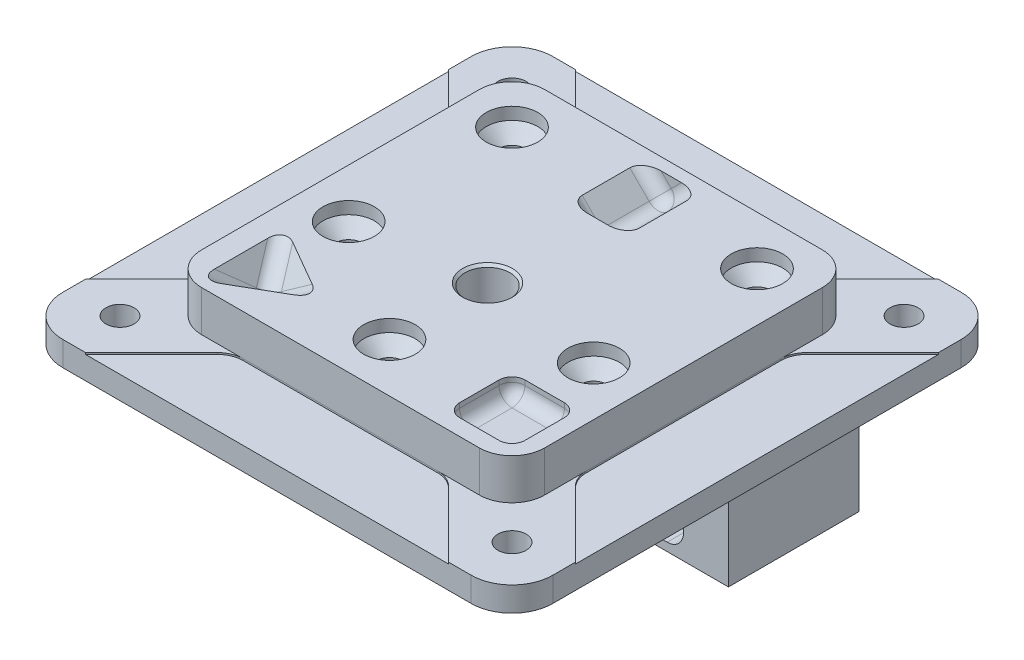
from build123d import *

# Parameters (mm, degrees)
SKETCH6_W                                      = 60
SKETCH6_H                                      = 60
PLATE_DEPTH                                    = 8
SKETCH7_W                                      = 60
SKETCH7_H                                      = 60
SKETCH7_W_2                                    = 42
SKETCH7_H_2                                    = 42
TOP_HAT_DEPTH                                  = 5
F_8_32_TAPPED_HOLE1_D                          = 3.4544
FILLET2_R                                      = 5
FILLET3_R                                      = 4
EXTRUDE8_DEPTH                                 = 0.2
BOSS_EXTRUDE1_DEPTH                            = 8
SKETCH25_R                                     = 1.986875
CUT_EXTRUDE1_DEPTH                             = 3.47375
CUT_EXTRUDE3_START                             = -19.986875
CUT_EXTRUDE3_DEPTH                             = 19.986875
FILLET4_R                                      = 1
BOSS_EXTRUDE2_DEPTH                            = 6.513125
F_4_40_TAPPED_HOLE2_D                          = 2.2606
F_4_40_TAPPED_HOLE2_DEPTH                      = 7.595
F_4_40_TAPPED_HOLE2_TIP                        = 0.679152758
CUT_EXTRUDE7_DEPTH                             = 10.25
SKETCH39_R                                     = 1.986875
CUT_EXTRUDE4_DEPTH                             = 10.25
CUT_EXTRUDE8_DEPTH                             = 5
BOSS_EXTRUDE3_DEPTH                            = 3
F_4_40_TAPPED_HOLE1_D                          = 2.2606
F_4_40_TAPPED_HOLE1_DEPTH                      = 7.595
F_4_40_TAPPED_HOLE1_TIP                        = 0.679152758
F_10_24_TAPPED_HOLE1_D                         = 3.7973
F_10_24_TAPPED_HOLE1_DEPTH                     = 15.878
F_10_24_TAPPED_HOLE1_CSINK_D                   = 6.096
F_10_24_TAPPED_HOLE1_CSINK_ANGLE               = 90
F_10_24_TAPPED_HOLE1_TIP                       = 1.140824014
PYR_DEPTH                                      = 40.339995873
SKETCH10_W                                     = 8
SKETCH10_H                                     = 8
EXTRUDE6_DEPTH                                 = 2.175
EXTRUDE7_DEPTH                                 = 4.5
FILLET1_R                                      = 1.5875
CUT_EXTRUDE13_DEPTH                            = 7
FILLET7_R                                      = 2
FILLET8_R                                      = 1
CSK_FOR_M3_FLAT_HEAD_MACHINE_SCREW1_AT_2_COUNT = 2
CSK_FOR_M3_FLAT_HEAD_MACHINE_SCREW1_AT_2_PITCH = 30
CSK_FOR_M3_FLAT_HEAD_MACHINE_SCREW1_AT_3_COUNT = 2
CSK_FOR_M3_FLAT_HEAD_MACHINE_SCREW1_AT_3_PITCH = 33.541019662
CSK_FOR_M3_FLAT_HEAD_MACHINE_SCREW1_AT_4_COUNT = 2
CSK_FOR_M3_FLAT_HEAD_MACHINE_SCREW1_AT_4_PITCH = 20
CSK_FOR_M3_FLAT_HEAD_MACHINE_SCREW1_AT_5_COUNT = 2
CSK_FOR_M3_FLAT_HEAD_MACHINE_SCREW1_AT_5_PITCH = 36.055512755
SKETCH61_W                                     = 1.25
SKETCH61_H                                     = 3
M3X0_5_TAPPED_HOLE2_AT_2_COUNT                 = 2
M3X0_5_TAPPED_HOLE2_AT_2_PITCH                 = 30
M3X0_5_TAPPED_HOLE2_AT_3_COUNT                 = 2
M3X0_5_TAPPED_HOLE2_AT_3_PITCH                 = 36.055512755
M3X0_5_TAPPED_HOLE2_AT_4_COUNT                 = 2
M3X0_5_TAPPED_HOLE2_AT_4_PITCH                 = 20
M3X0_5_TAPPED_HOLE2_AT_5_COUNT                 = 2
M3X0_5_TAPPED_HOLE2_AT_5_PITCH                 = 18.027756377
SKETCH63_R                                     = 2.75
CUT_EXTRUDE14_DEPTH                            = 29


with BuildPart() as part:
    # Sketch6 → plate (new body)
    with BuildSketch(Plane(origin=(0, 0, 0), x_dir=(1, 0, 0), z_dir=(0, 1, 0))):
        Rectangle(SKETCH6_W, SKETCH6_H)
    extrude(amount=PLATE_DEPTH)

    # Sketch7 → top hat (cut)
    with BuildSketch(Plane(origin=(0, 8, 0), x_dir=(1, 0, 0), z_dir=(0, 1, 0))):
        Rectangle(SKETCH7_W, SKETCH7_H)
        Rectangle(SKETCH7_W_2, SKETCH7_H_2, mode=Mode.SUBTRACT)
    extrude(amount=-TOP_HAT_DEPTH, mode=Mode.SUBTRACT)

    # #8-32 Tapped Hole1 (through all)
    with Locations(Plane(origin=(-24, 3, -24), x_dir=(0, 0, 1), z_dir=(0, 1, 0))):
        with Locations((0, 0), (0, 48), (48, 48), (48, 0)):
            Hole(F_8_32_TAPPED_HOLE1_D / 2)

    # Fillet2
    fillet2_edges = [part.edges().sort_by_distance(p)[0] for p in [
        (30, 1.5, 30),
        (-30, 1.5, 30),
        (-30, 1.5, -30),
        (30, 1.5, -30),
    ]]
    fillet(fillet2_edges, radius=FILLET2_R)

    # Fillet3
    fillet3_edges = [part.edges().sort_by_distance(p)[0] for p in [
        (-21, 5.5, 21),
        (-21, 5.5, -21),
        (21, 5.5, -21),
        (21, 5.5, 21),
    ]]
    fillet(fillet3_edges, radius=FILLET3_R)

    # Sketch15 → Extrude8 (cut)
    with BuildSketch(Plane(origin=(0, 3, 0), x_dir=(1, 0, 0), z_dir=(0, 1, 0))):
        with BuildLine():
            Line((30, 22.221825407), (30, -22.221825407))
            Line((30, -22.221825407), (21.92993597, -14.151761377))
            ThreePointArc((21.92993597, -14.151761377), (21.241682484, -13.121717244), (21, -11.906697346))
            Line((21, -11.906697346), (21, 11.906697346))
            ThreePointArc((21, 11.906697346), (21.241682484, 13.121717244), (21.92993597, 14.151761377))
            Line((21.92993597, 14.151761377), (30, 22.221825407))
        make_face()
        with BuildLine():
            Line((11.906697346, -21), (-11.906697346, -21))
            ThreePointArc((-11.906697346, -21), (-13.121717244, -21.241682484), (-14.151761377, -21.92993597))
            Line((-14.151761377, -21.92993597), (-22.221825407, -30))
            Line((-22.221825407, -30), (22.221825407, -30))
            Line((22.221825407, -30), (14.151761377, -21.92993597))
            ThreePointArc((14.151761377, -21.92993597), (13.121717244, -21.241682484), (11.906697346, -21))
        make_face()
        with BuildLine():
            Line((-30, -22.221825407), (-30, 22.221825407))
            Line((-30, 22.221825407), (-21.92993597, 14.151761377))
            ThreePointArc((-21.92993597, 14.151761377), (-21.241682484, 13.121717244), (-21, 11.906697346))
            Line((-21, 11.906697346), (-21, -11.906697346))
            ThreePointArc((-21, -11.906697346), (-21.241682484, -13.121717244), (-21.92993597, -14.151761377))
            Line((-21.92993597, -14.151761377), (-30, -22.221825407))
        make_face()
        with BuildLine():
            Line((22.221825407, 30), (-22.221825407, 30))
            Line((-22.221825407, 30), (-14.151761377, 21.92993597))
            ThreePointArc((-14.151761377, 21.92993597), (-13.121717244, 21.241682484), (-11.906697346, 21))
            Line((-11.906697346, 21), (11.906697346, 21))
            ThreePointArc((11.906697346, 21), (13.121717244, 21.241682484), (14.151761377, 21.92993597))
            Line((14.151761377, 21.92993597), (22.221825407, 30))
        make_face()
    extrude(amount=-EXTRUDE8_DEPTH, mode=Mode.SUBTRACT)



with BuildPart() as body_2:
    # Sketch24 → Boss-Extrude1 (new body, symmetric)
    with BuildSketch(Plane(origin=(-11, 0, 0), x_dir=(0, 0, -1), z_dir=(1, 0, 0))):
        Polygon((0.763125, 2.8), (23.486875, 2.8), (23.486875, -10.513125), (23.486875, -20), (-8, -20), (-8, 2.8), align=None)
    extrude(amount=BOSS_EXTRUDE1_DEPTH, both=True)

    # Sketch25 → Cut-Extrude1 (cut)
    with BuildSketch(Plane(origin=(0, 0, -23.486875), x_dir=(-1, 0, 0), z_dir=(0, 0, -1))):
        with Locations((16, -13)):
            Circle(SKETCH25_R)
        with Locations((6, -13)):
            Circle(SKETCH25_R)
    extrude(amount=-CUT_EXTRUDE1_DEPTH, mode=Mode.SUBTRACT)

    # Sketch26 → Cut-Extrude3 (cut)
    with BuildSketch(Plane(origin=(0, 0, -23.486875), x_dir=(-1, 0, 0), z_dir=(0, 0, -1)).offset(CUT_EXTRUDE3_START)):
        with BuildLine():
            Line((4.585786438, -10.525126266), (8.5, -14.439339828))
            Line((8.5, -14.439339828), (8.5, -17))
            ThreePointArc((8.5, -17), (9.085786438, -18.414213562), (10.5, -19))
            Line((10.5, -19), (11.5, -19))
            ThreePointArc((11.5, -19), (12.914213562, -18.414213562), (13.5, -17))
            Line((13.5, -17), (13.5, -14.439339828))
            Line((13.5, -14.439339828), (17.414213562, -10.525126266))
            ThreePointArc((17.414213562, -10.525126266), (17.847759065, -9.876279568), (18, -9.110912703))
            Line((18, -9.110912703), (18, -5.525126266))
            Line((18, -5.525126266), (18, -2))
            ThreePointArc((18, -2), (17.414213562, -0.585786438), (16, 0))
            Line((16, 0), (6, 0))
            ThreePointArc((6, 0), (4.585786438, -0.585786438), (4, -2))
            Line((4, -2), (4, -5.525126266))
            Line((4, -5.525126266), (4, -9.110912703))
            ThreePointArc((4, -9.110912703), (4.152240935, -9.876279568), (4.585786438, -10.525126266))
        make_face()
    extrude(amount=CUT_EXTRUDE3_DEPTH, mode=Mode.SUBTRACT)

    # Fillet4
    fillet4_edges = [body_2.edges().sort_by_distance(p)[0] for p in [
        (-8.5, -14.439339828, -13.4934375),
        (-13.5, -14.439339828, -13.4934375),
    ]]
    fillet(fillet4_edges, radius=FILLET4_R)


with BuildPart() as part_1:
    add(part.part)

    add(body_2.part)  # Boss-Extrude2 merges body 2
    # Sketch28 → Boss-Extrude2 (add)
    with BuildSketch(Plane(origin=(0, 0, -23.486875), x_dir=(-1, 0, 0), z_dir=(0, 0, -1))):
        with BuildLine():
            Line((4, -2), (4, -9.110912703))
            Line((4, -9.110912703), (3, -9.110912703))
            Line((3, -9.110912703), (3, 2.8))
            Line((3, 2.8), (19, 2.8))
            Line((19, 2.8), (19, -9.110912703))
            Line((19, -9.110912703), (18, -9.110912703))
            Line((18, -9.110912703), (18, -2))
            ThreePointArc((18, -2), (17.414213562, -0.585786438), (16, 0))
            Line((16, 0), (6, 0))
            ThreePointArc((6, 0), (4.585786438, -0.585786438), (4, -2))
        make_face()
    extrude(amount=BOSS_EXTRUDE2_DEPTH)

    # #4-40 Tapped Hole2
    with Locations(Plane(origin=(0, 0, -23.486875), x_dir=(-1, 0, 0), z_dir=(0, 0, -1))):
        with Locations((16, -17), (6, -17)):
            Hole(F_4_40_TAPPED_HOLE2_D / 2, depth=F_4_40_TAPPED_HOLE2_DEPTH)
            with Locations((0, 0, -(F_4_40_TAPPED_HOLE2_DEPTH + F_4_40_TAPPED_HOLE2_TIP / 2))):  # 118° drill point
                Cone(0, F_4_40_TAPPED_HOLE2_D / 2, F_4_40_TAPPED_HOLE2_TIP, mode=Mode.SUBTRACT)

    # Sketch44 → Cut-Extrude7 (cut)
    with BuildSketch(Plane.ZY.offset(19)):
        with BuildLine():
            Line((8, 0), (-3.5, 0))
            ThreePointArc((-3.5, 0), (-6.328427125, -1.171572875), (-7.5, -4))
            Line((-7.5, -4), (-7.5, -13))
            Line((-7.5, -13), (-7.5, -20))
            Line((-7.5, -20), (8, -20))
            Line((8, -20), (8, -17))
            Line((8, -17), (8, -13))
            Line((8, -13), (8, -4))
            Line((8, -4), (8, 0))
        make_face()
        with BuildLine():
            Line((1, -12.5), (-2.25, -12.5))
            ThreePointArc((-2.25, -12.5), (-3.133883476, -12.133883476), (-3.5, -11.25))
            Line((-3.5, -11.25), (-3.5, -5.75))
            ThreePointArc((-3.5, -5.75), (-3.133883476, -4.866116524), (-2.25, -4.5))
            Line((-2.25, -4.5), (1, -4.5))
            ThreePointArc((1, -4.5), (1.883883476, -4.866116524), (2.25, -5.75))
            Line((2.25, -5.75), (2.25, -11.25))
            ThreePointArc((2.25, -11.25), (1.883883476, -12.133883476), (1, -12.5))
        make_face(mode=Mode.SUBTRACT)
    extrude(amount=-CUT_EXTRUDE7_DEPTH, mode=Mode.SUBTRACT)

    # Sketch39 → Cut-Extrude4 (cut)
    with BuildSketch(Plane.ZY.offset(19)):
        with Locations((-2.75, -8.5)):
            Circle(SKETCH39_R)
    extrude(amount=-CUT_EXTRUDE4_DEPTH, mode=Mode.SUBTRACT)

    # Sketch45 → Cut-Extrude8 (cut)
    with BuildSketch(Plane.ZY.offset(19)):
        with BuildLine():
            Line((2.25, -11.25), (2.25, -5.75))
            ThreePointArc((2.25, -5.75), (1.883883476, -4.866116524), (1, -4.5))
            Line((1, -4.5), (-2.25, -4.5))
            ThreePointArc((-2.25, -4.5), (-3.133883476, -4.866116524), (-3.5, -5.75))
            Line((-3.5, -5.75), (-3.5, -6.660116236))
            ThreePointArc((-3.5, -6.660116236), (-0.763125, -8.5), (-3.5, -10.339883764))
            Line((-3.5, -10.339883764), (-3.5, -11.25))
            ThreePointArc((-3.5, -11.25), (-3.133883476, -12.133883476), (-2.25, -12.5))
            Line((-2.25, -12.5), (1, -12.5))
            ThreePointArc((1, -12.5), (1.883883476, -12.133883476), (2.25, -11.25))
        make_face()
    extrude(amount=-CUT_EXTRUDE8_DEPTH, mode=Mode.SUBTRACT)

    # Sketch38 → Boss-Extrude3 (add)
    with BuildSketch(Plane(origin=(-3, 0, 0), x_dir=(0, 0, -1), z_dir=(1, 0, 0))):
        Polygon((30, -9.110912703), (30, 0), (-8, 0), (-8, -20), (23.486875, -20), (23.486875, -9.110912703), align=None)
    extrude(amount=BOSS_EXTRUDE3_DEPTH)

    # #4-40 Tapped Hole1
    with Locations(Plane.ZY.offset(8.75)):
        with Locations((5.25, -16.5), (-0.75, -16.5)):
            Hole(F_4_40_TAPPED_HOLE1_D / 2, depth=F_4_40_TAPPED_HOLE1_DEPTH)
            with Locations((0, 0, -(F_4_40_TAPPED_HOLE1_DEPTH + F_4_40_TAPPED_HOLE1_TIP / 2))):  # 118° drill point
                Cone(0, F_4_40_TAPPED_HOLE1_D / 2, F_4_40_TAPPED_HOLE1_TIP, mode=Mode.SUBTRACT)


with BuildPart() as body_2_2:
    # Mirror11: mirrored copy
    add(part_1.part.mirror(Plane(origin=(0, 0, 0), x_dir=(0, 0, 1), z_dir=(1, 0, 0))))


with BuildPart() as part_2:
    add(part_1.part)

    # Combine1: union body 2 2
    add(body_2_2.part)

    # #10-24 Tapped Hole1
    with Locations(Plane(origin=(0, 8, 3), x_dir=(0, 0, 1), z_dir=(0, 1, 0))):
        with Locations((0, 0)):
            CounterSinkHole(F_10_24_TAPPED_HOLE1_D / 2, F_10_24_TAPPED_HOLE1_CSINK_D / 2, depth=F_10_24_TAPPED_HOLE1_DEPTH, counter_sink_angle=F_10_24_TAPPED_HOLE1_CSINK_ANGLE)
            with Locations((0, 0, -(F_10_24_TAPPED_HOLE1_DEPTH + F_10_24_TAPPED_HOLE1_TIP / 2))):  # 118° drill point
                Cone(0, F_10_24_TAPPED_HOLE1_D / 2, F_10_24_TAPPED_HOLE1_TIP, mode=Mode.SUBTRACT)

    # Sketch9 → pyr (cut, through all)
    with BuildSketch(Plane(origin=(-8.349735957, -5.904154917, 0), x_dir=(0, 0, -1), z_dir=(0.816496581, 0.577350269, 0))):
        Polygon((-20.510447219, 17.029042425), (-9.489552781, 17.029042425), (-15, 11.518595206), align=None)
    extrude(amount=PYR_DEPTH, mode=Mode.SUBTRACT)

    # Sketch10 → Extrude6 (cut)
    with BuildSketch(Plane(origin=(0, 8, 0), x_dir=(1, 0, 0), z_dir=(0, 1, 0))):
        with Locations((15, -15)):
            Rectangle(SKETCH10_W, SKETCH10_H)
    extrude(amount=-EXTRUDE6_DEPTH, mode=Mode.SUBTRACT)

    # Sketch11 → Extrude7 (cut, symmetric)
    with BuildSketch(Plane.XY.offset(-15)):
        Polygon((-7.665128061, 12.175), (7.665128061, 12.175), (0, 4.509871939), align=None)
    extrude(amount=EXTRUDE7_DEPTH, both=True, mode=Mode.SUBTRACT)

    # Fillet1
    fillet1_edges = [part_2.edges().sort_by_distance(p)[0] for p in [
        (-16.590729093, 5.750369343, 17.75522361),
        (-16.590729093, 5.750369343, 12.24477639),
        (-11.818541815, 5.750369343, 15),
        (11, 5.825, 15),
        (11, 6.9125, 19),
        (15, 5.825, 11),
        (11, 6.9125, 11),
        (19, 5.825, 15),
        (19, 6.9125, 11),
        (15, 5.825, 19),
        (19, 6.9125, 19),
        (-1.74506403, 6.25493597, -19.5),
        (0, 4.509871939, -15),
        (1.74506403, 6.25493597, -19.5),
        (-1.74506403, 6.25493597, -10.5),
        (1.74506403, 6.25493597, -10.5),
    ]]
    fillet(fillet1_edges, radius=FILLET1_R)

    # Sketch62 → Cut-Extrude13 (cut)
    with BuildSketch(Plane.XZ.offset(20)):
        Polygon((2, -4), (5.25, -4), (5.25, 8), (-5.25, 8), (-5.25, -4), (-2, -4), (-2, -23.486875), (2, -23.486875), align=None)
    extrude(amount=-CUT_EXTRUDE13_DEPTH, mode=Mode.SUBTRACT)

    # Fillet7
    fillet7_edges = [part_2.edges().sort_by_distance(p)[0] for p in [
        (-5.25, -16.5, -4),
        (5.25, -16.5, -4),
    ]]
    fillet(fillet7_edges, radius=FILLET7_R)

    # Fillet8
    fillet8_edges = [part_2.edges().sort_by_distance(p)[0] for p in [
        (2, -16.5, -4),
        (-2, -16.5, -4),
    ]]
    fillet(fillet8_edges, radius=FILLET8_R)


with BuildPart() as body_2_3:
    # Split1: the piece on the far side of the plane
    add(part_2.part)
    split(bisect_by=Plane.ZX.offset(3), keep=Keep.BOTTOM)

    # Sketch61 → M3x0.5 Tapped Hole2 (revolve, cut)
    with BuildSketch(Plane(origin=(15, 3, 5), x_dir=(0, 0, 1), z_dir=(1, 0, 0))):
        with Locations((0.625, 1.5)):
            Rectangle(SKETCH61_W, SKETCH61_H)
    m3x0_5_tapped_hole2 = revolve(axis=Axis((15, 9.35, 5), (0, -1, 0)), mode=Mode.SUBTRACT)

    # M3x0.5 Tapped Hole2 at 2: M3x0.5 Tapped Hole2 ×2
    with Locations(*[(-i * M3X0_5_TAPPED_HOLE2_AT_2_PITCH, 0, 0) for i in range(1, M3X0_5_TAPPED_HOLE2_AT_2_COUNT)]):
        add(m3x0_5_tapped_hole2, mode=Mode.SUBTRACT)

    # M3x0.5 Tapped Hole2 at 3: M3x0.5 Tapped Hole2 ×2
    with Locations(*[Vector(-0.832050294, 0, -0.554700196) * (i * M3X0_5_TAPPED_HOLE2_AT_3_PITCH) for i in range(1, M3X0_5_TAPPED_HOLE2_AT_3_COUNT)]):
        add(m3x0_5_tapped_hole2, mode=Mode.SUBTRACT)

    # M3x0.5 Tapped Hole2 at 4: M3x0.5 Tapped Hole2 ×2
    with Locations(*[(0, 0, -i * M3X0_5_TAPPED_HOLE2_AT_4_PITCH) for i in range(1, M3X0_5_TAPPED_HOLE2_AT_4_COUNT)]):
        add(m3x0_5_tapped_hole2, mode=Mode.SUBTRACT)

    # M3x0.5 Tapped Hole2 at 5: M3x0.5 Tapped Hole2 ×2
    with Locations(*[Vector(-0.832050294, 0, 0.554700196) * (i * M3X0_5_TAPPED_HOLE2_AT_5_PITCH) for i in range(1, M3X0_5_TAPPED_HOLE2_AT_5_COUNT)]):
        add(m3x0_5_tapped_hole2, mode=Mode.SUBTRACT)


with BuildPart() as part_3:
    add(part_2.part)

    # Split1
    split(bisect_by=Plane.ZX.offset(3), keep=Keep.TOP)

    # Sketch57 → CSK for M3 Flat Head Machine Screw1 (revolve, cut)
    with BuildSketch(Plane(origin=(15, 8, -15), x_dir=(0, 0, 1), z_dir=(1, 0, 0))):
        Polygon((0, 0), (0, 5.96037699), (1.6, 4.999), (1.6, 3.05), (3.15, 1.5), (3.15, 0), align=None)
    csk_for_m3_flat_head_machine_screw1 = revolve(axis=Axis((15, 14.35, -15), (0, -1, 0)), mode=Mode.SUBTRACT)

    # CSK for M3 Flat Head Machine Screw1 at 2: CSK for M3 Flat Head Machine Screw1 ×2
    with Locations(*[(-i * CSK_FOR_M3_FLAT_HEAD_MACHINE_SCREW1_AT_2_PITCH, 0, 0) for i in range(1, CSK_FOR_M3_FLAT_HEAD_MACHINE_SCREW1_AT_2_COUNT)]):
        add(csk_for_m3_flat_head_machine_screw1, mode=Mode.SUBTRACT)

    # CSK for M3 Flat Head Machine Screw1 at 3: CSK for M3 Flat Head Machine Screw1 ×2
    with Locations(*[Vector(-0.447213595, 0, 0.894427191) * (i * CSK_FOR_M3_FLAT_HEAD_MACHINE_SCREW1_AT_3_PITCH) for i in range(1, CSK_FOR_M3_FLAT_HEAD_MACHINE_SCREW1_AT_3_COUNT)]):
        add(csk_for_m3_flat_head_machine_screw1, mode=Mode.SUBTRACT)

    # CSK for M3 Flat Head Machine Screw1 at 4: CSK for M3 Flat Head Machine Screw1 ×2
    with Locations(*[(0, 0, i * CSK_FOR_M3_FLAT_HEAD_MACHINE_SCREW1_AT_4_PITCH) for i in range(1, CSK_FOR_M3_FLAT_HEAD_MACHINE_SCREW1_AT_4_COUNT)]):
        add(csk_for_m3_flat_head_machine_screw1, mode=Mode.SUBTRACT)

    # CSK for M3 Flat Head Machine Screw1 at 5: CSK for M3 Flat Head Machine Screw1 ×2
    with Locations(*[Vector(-0.832050294, 0, 0.554700196) * (i * CSK_FOR_M3_FLAT_HEAD_MACHINE_SCREW1_AT_5_PITCH) for i in range(1, CSK_FOR_M3_FLAT_HEAD_MACHINE_SCREW1_AT_5_COUNT)]):
        add(csk_for_m3_flat_head_machine_screw1, mode=Mode.SUBTRACT)

    # Sketch63 → Cut-Extrude14 (cut, through all)
    with BuildSketch(Plane(origin=(0, 8, 0), x_dir=(1, 0, 0), z_dir=(0, 1, 0))):
        with Locations(Location((0, -3, 0), (0, 0, 270))):  # turned: the seam where the file's is
            Circle(SKETCH63_R)
    extrude(amount=-CUT_EXTRUDE14_DEPTH, mode=Mode.SUBTRACT)


solid = Compound([body_2_3.part, part_3.part])
